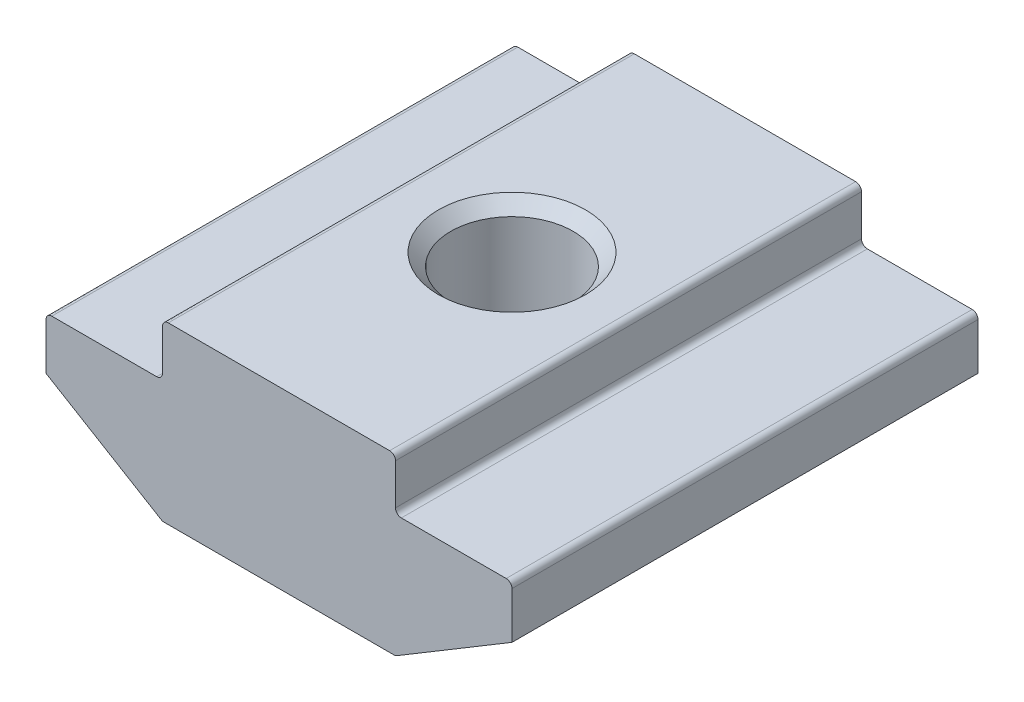
from build123d import *

# Parameters (mm, degrees)
EXTRUDE_1_DEPTH = 8
FILLET_1_R      = 0.2


with BuildPart() as part:
    # Эскиз1 → Бобышка-Вытянуть1 (new body, symmetric)
    with BuildSketch(Plane.XY):
        Polygon((4, 0), (-4, 0), (-4, -1.8), (-8, -1.8), (-8, -3.6), (-4, -6), (4, -6), (8, -3.6), (8, -1.8), (4, -1.8), align=None)
    extrude(amount=EXTRUDE_1_DEPTH, both=True)

    # Эскиз4 → Отверстие обработанное метчиком M52 (revolve, cut)
    with BuildSketch(Plane(origin=(0, 0, 0), x_dir=(0, 0, 1), z_dir=(1, 0, 0))):
        Polygon((0, 0), (0, 6), (2.525, 6), (2.1, 5.575), (2.1, 0.425), (2.525, 0), align=None)
    revolve(axis=Axis((0, 6.35, 0), (0, -1, 0)), mode=Mode.SUBTRACT)

    # Скругление1
    fillet_1_edges = [part.edges().sort_by_distance(p)[0] for p in [
        (-4, 0, 0),
        (4, 0, 0),
        (4, -1.8, 0),
        (8, -1.8, 0),
        (4, -6, 0),
        (-4, -6, 0),
        (-8, -1.8, 0),
        (-4, -1.8, 0),
    ]]
    fillet(fillet_1_edges, radius=FILLET_1_R)


solid = part.part
